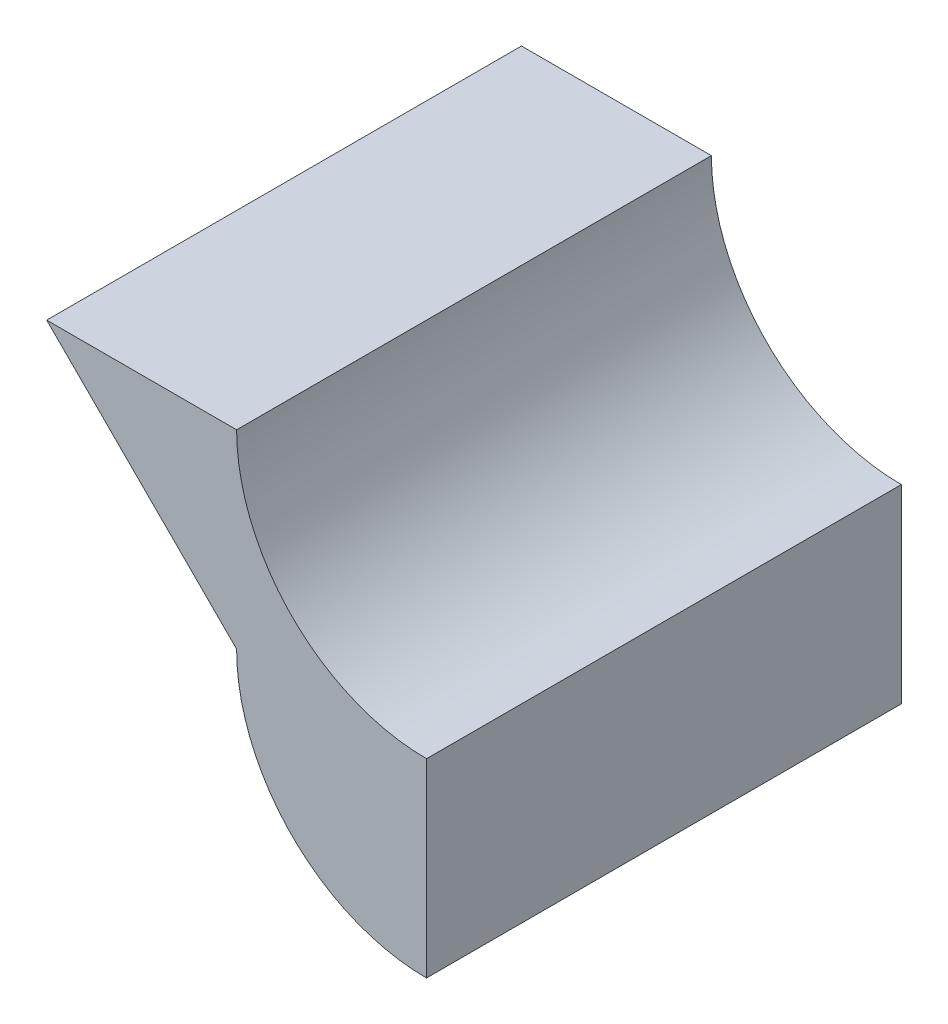
from build123d import *

# Parameters (mm, degrees)
BOSS_EXTRUDE1_DEPTH = 25


with BuildPart() as part:
    # Sketch1 → Boss-Extrude1 (new body)
    with BuildSketch(Plane.XY):
        with BuildLine():
            Line((-20, 20), (-10, 20))
            ThreePointArc((-10, 20), (-7.071067812, 12.928932188), (0, 10))
            Line((0, 10), (0, 0))
            ThreePointArc((0, 0), (-7.071067812, 2.928932188), (-10, 10))
            Line((-10, 10), (-20, 20))
        make_face()
    extrude(amount=BOSS_EXTRUDE1_DEPTH)


solid = part.part
